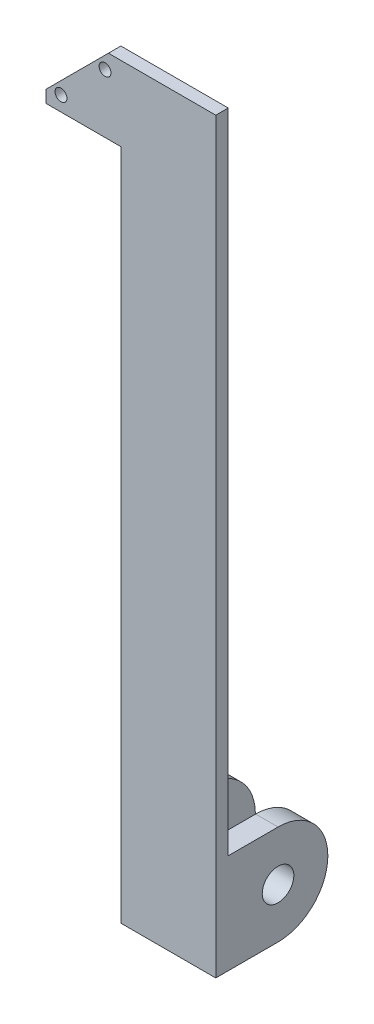
from build123d import *

# Parameters (mm, degrees)
SKETCH1_W           = 38.1
SKETCH1_H           = 300
BOSS_EXTRUDE1_DEPTH = 5
SKETCH4_W           = 9
SKETCH4_H           = 40
BOSS_EXTRUDE3_DEPTH = 40
CUT_EXTRUDE2_DEPTH  = 40


with BuildPart() as part:
    # Sketch1 → Boss-Extrude1 (new body)
    with BuildSketch(Plane.XY):
        with BuildLine():
            Line((-30, 275), (-30, 270))
            Line((-30, 270), (-25.725428583, 274.274571417))
            ThreePointArc((-25.725428583, 274.274571417), (-25.725428583, 277.642167462), (-22.357832538, 277.642167462))
            Line((-22.357832538, 277.642167462), (-8.047759053, 291.952240947))
            ThreePointArc((-8.047759053, 291.952240947), (-8.047759053, 295.319836992), (-4.680163008, 295.319836992))
            Line((-4.680163008, 295.319836992), (0, 300))
            Line((0, 300), (-5, 300))
            Line((-5, 300), (-30, 275))
        make_face()
        with BuildLine():
            Line((-25.725428583, 274.274571417), (-30, 270))
            Line((-30, 270), (0, 270))
            Line((0, 270), (0, 300))
            Line((0, 300), (-4.680163008, 295.319836992))
            ThreePointArc((-4.680163008, 295.319836992), (-4.163972894, 294.547303893), (-3.982711031, 293.636038969))
            ThreePointArc((-3.982711031, 293.636038969), (-5.452696107, 291.436050833), (-8.047759053, 291.952240947))
            Line((-8.047759053, 291.952240947), (-22.357832538, 277.642167462))
            ThreePointArc((-22.357832538, 277.642167462), (-21.841642424, 276.869634363), (-21.66038056, 275.95836944))
            ThreePointArc((-21.66038056, 275.95836944), (-23.130365637, 273.758381303), (-25.725428583, 274.274571417))
        make_face()
        with Locations((19.05, 150)):
            Rectangle(SKETCH1_W, SKETCH1_H)
    extrude(amount=BOSS_EXTRUDE1_DEPTH)

    # Sketch4 → Boss-Extrude3 (add)
    with BuildSketch(Plane(origin=(0, 0, 0), x_dir=(-1, 0, 0), z_dir=(0, 0, -1))):
        with Locations((-33.6, 20)):
            Rectangle(SKETCH4_W, SKETCH4_H)
        with Locations((-4.5, 20)):
            Rectangle(SKETCH4_W, SKETCH4_H)
    extrude(amount=BOSS_EXTRUDE3_DEPTH)

    # Sketch5 → Cut-Extrude2 (cut)
    with BuildSketch(Plane(origin=(38.1, 0, 0), x_dir=(0, 0, -1), z_dir=(1, 0, 0))):
        with BuildLine():
            Line((40, 20.01), (40, 40))
            Line((40, 40), (34.145064556, 34.145064556))
            ThreePointArc((34.145064556, 34.145064556), (38.478351855, 27.659841813), (40, 20.01))
        make_face()
        with BuildLine():
            Line((34.145064556, 34.145064556), (40, 40))
            Line((40, 40), (20.01, 40))
            ThreePointArc((20.01, 40), (27.659841813, 38.478351855), (34.145064556, 34.145064556))
        make_face()
        with BuildLine():
            ThreePointArc((26.35, 20), (25.866635031, 22.430039796), (24.490128061, 24.490128061))
            Line((24.490128061, 24.490128061), (15.509871939, 15.509871939))
            ThreePointArc((15.509871939, 15.509871939), (22.430039796, 14.133364969), (26.35, 20))
        make_face()
        with BuildLine():
            Line((15.509871939, 15.509871939), (24.490128061, 24.490128061))
            ThreePointArc((24.490128061, 24.490128061), (15.509871939, 24.490128061), (15.509871939, 15.509871939))
        make_face()
        with BuildLine():
            Line((40, 0), (40, 19.99))
            ThreePointArc((40, 19.99), (34.145064556, 5.854935444), (20.01, 0))
            Line((20.01, 0), (40, 0))
        make_face()
    extrude(amount=-CUT_EXTRUDE2_DEPTH, mode=Mode.SUBTRACT)


solid = part.part
